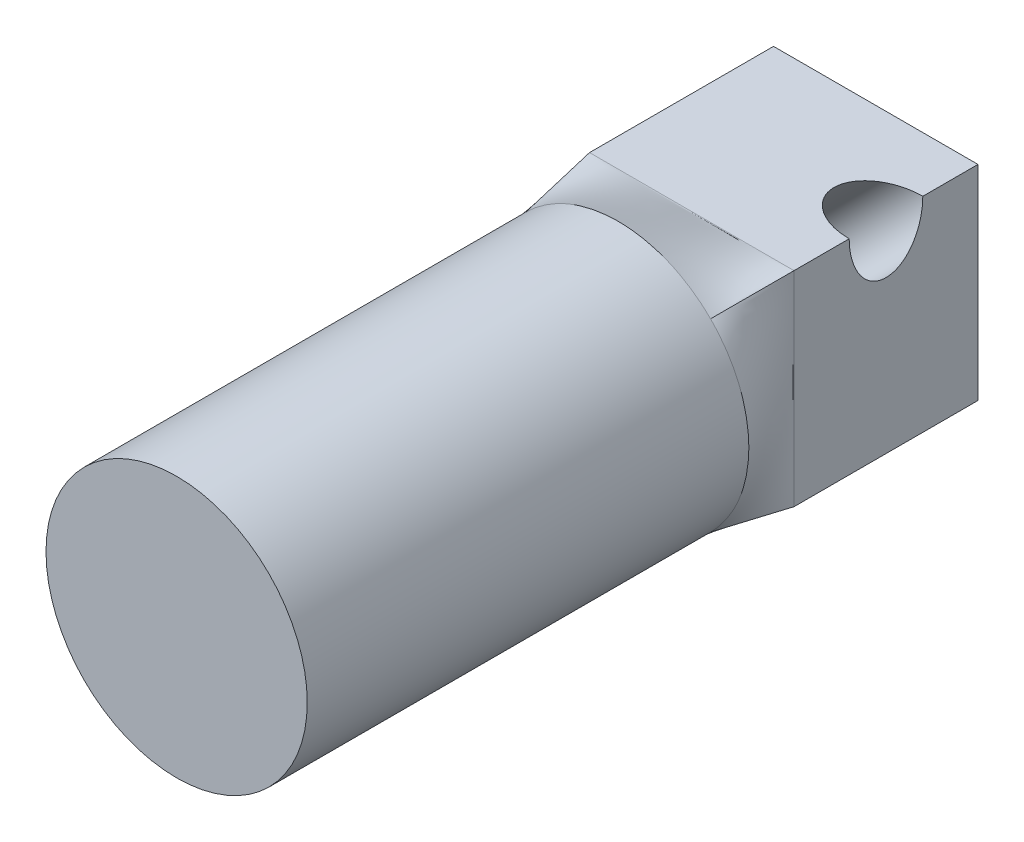
from build123d import *

# Parameters (mm, degrees)
SKETCH3_W           = 5.55685425
SKETCH3_H           = 5.55685425
BOSS_EXTRUDE1_DEPTH = 5
BOSS_EXTRUDE2_DEPTH = 12
SKETCH5_R           = 1
CUT_EXTRUDE1_DEPTH  = 5


with BuildPart() as part:
    # Sketch1 → Loft1 section 0
    with BuildSketch(Plane.XY):
        with BuildLine():
            Line((2.778427125, 2.778427125), (-2.778427125, 2.778427125))
            Line((-2.778427125, 2.778427125), (-2.778427125, -2.778427125))
            Line((-2.778427125, -2.778427125), (2.778427125, -2.778427125))
            Line((2.778427125, -2.778427125), (2.778427125, 2.778427125))
        make_face()
    # Sketch2 for Loft1 → Loft1 section 1
    with BuildSketch(Plane.XY.offset(2)):
        with BuildLine():
            # circular arc as an exact rational Bezier (weights 1, cos(half-angle), 1)
            Bezier((2.510229073, 2.510229073), (0, 5.020458147), (-2.510229073, 2.510229073), weights=[1, 0.707106781, 1])
            Bezier((-2.510229073, 2.510229073), (-5.020458147, 0), (-2.510229073, -2.510229073), weights=[1, 0.707106781, 1])
            Bezier((-2.510229073, -2.510229073), (0, -5.020458147), (2.510229073, -2.510229073), weights=[1, 0.707106781, 1])
            Bezier((2.510229073, -2.510229073), (5.020458147, 0), (2.510229073, 2.510229073), weights=[1, 0.707106781, 1])
        make_face()
    loft()

    # Sketch3 → Boss-Extrude1 (add)
    with BuildSketch(Plane(origin=(0, 0, 0), x_dir=(-1, 0, 0), z_dir=(0, 0, -1))):
        Rectangle(SKETCH3_W, SKETCH3_H)
    extrude(amount=BOSS_EXTRUDE1_DEPTH)

    # Sketch4 → Boss-Extrude2 (add)
    with BuildSketch(Plane.XY.offset(2)):
        with BuildLine():
            ThreePointArc((2.510229073, 2.510229073), (0, 3.55), (-2.510229073, 2.510229073))
            ThreePointArc((-2.510229073, 2.510229073), (-3.55, 0), (-2.510229073, -2.510229073))
            ThreePointArc((-2.510229073, -2.510229073), (0, -3.55), (2.510229073, -2.510229073))
            ThreePointArc((2.510229073, -2.510229073), (3.55, 0), (2.510229073, 2.510229073))
        make_face()
    extrude(amount=BOSS_EXTRUDE2_DEPTH)

    # Sketch5 → Cut-Extrude1 (cut, symmetric)
    with BuildSketch(Plane(origin=(0, 0, 0), x_dir=(0, 0, -1), z_dir=(0.7071067811865488, 0.7071067811865464, 0))):
        with Locations((2.5, 0)):
            Circle(SKETCH5_R)
    extrude(amount=CUT_EXTRUDE1_DEPTH, both=True, mode=Mode.SUBTRACT)


solid = part.part
